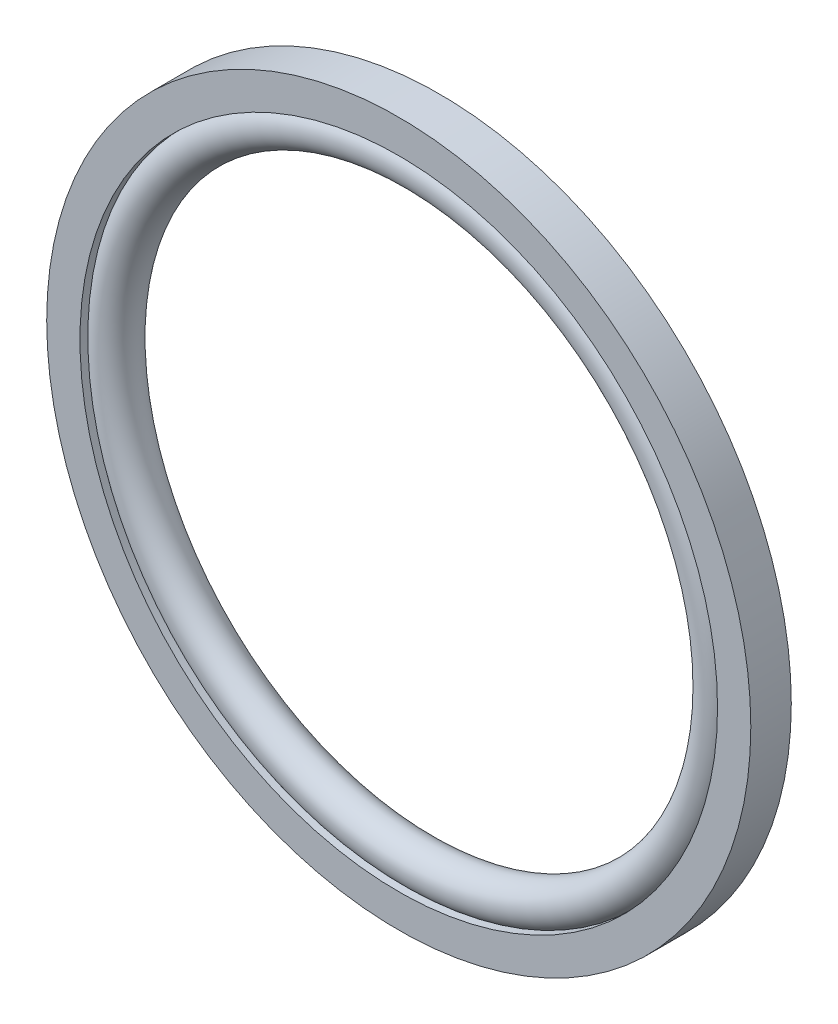
from build123d import *

# Parameters (mm, degrees)
SKETCH2_W = 2.921
SKETCH2_H = 2.4003


with BuildPart() as part:
    # Sketch2 → Revolve1 (revolve)
    with BuildSketch(Plane(origin=(0, 0, 0), x_dir=(0, 0, -1), z_dir=(1, 0, 0))):
        with Locations((0, 24.19985)):
            Rectangle(SKETCH2_W, SKETCH2_H)
    revolve(axis=Axis((0, 0, 1.4605), (0, 0, -1)))


with BuildPart() as body_2:
    # Sketch3 → Revolve2 (revolve)
    with BuildSketch(Plane(origin=(0, 0, 0), x_dir=(0, 0, -1), z_dir=(1, 0, 0))):
        with BuildLine():
            Line((-0.8763, 22.9997), (0.8763, 22.9997))
            ThreePointArc((0.8763, 22.9997), (0, 20.3708), (-0.8763, 22.9997))
        make_face()
    revolve(axis=Axis((0, 0, 1.4605), (0, 0, -1)))


solid = Compound([part.part, body_2.part])
